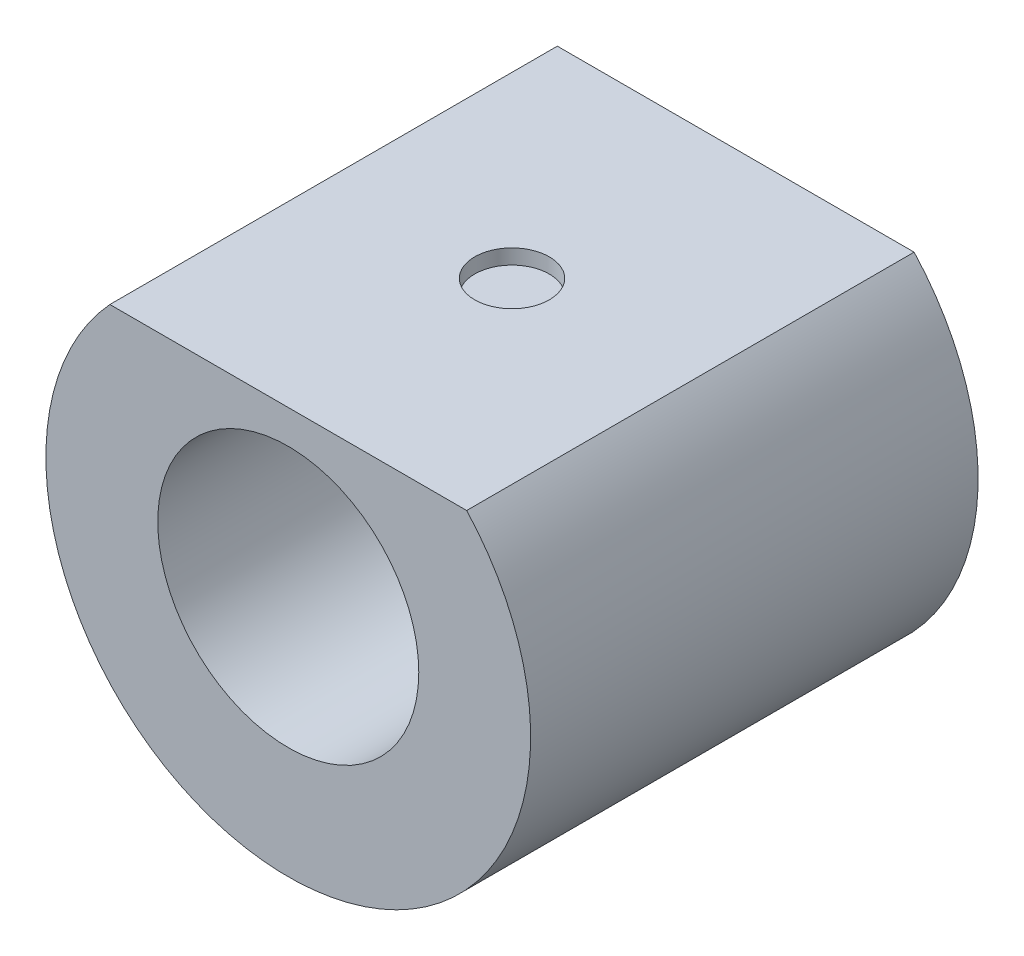
from build123d import *

# Parameters (mm, degrees)
SKETCH1_R           = 32.5
BOSS_EXTRUDE1_DEPTH = 60
SKETCH3_R           = 17.5
CUT_EXTRUDE4_DEPTH  = 52
SKETCH6_R           = 6.5
CUT_EXTRUDE5_DEPTH  = 8
SKETCH8_W           = 65.355871795
SKETCH8_H           = 11.921493712
CUT_EXTRUDE6_DEPTH  = 60
SKETCH9_R           = 5
CUT_EXTRUDE9_DEPTH  = 2


with BuildPart() as part:
    # Sketch1 → Boss-Extrude1 (new body)
    with BuildSketch(Plane.XY):
        Circle(SKETCH1_R)
    extrude(amount=BOSS_EXTRUDE1_DEPTH)

    # Sketch3 → Cut-Extrude4 (cut)
    with BuildSketch(Plane.XY.offset(60)):
        Circle(SKETCH3_R)
    extrude(amount=-CUT_EXTRUDE4_DEPTH, mode=Mode.SUBTRACT)

    # Sketch6 → Cut-Extrude5 (cut)
    with BuildSketch(Plane.XY.offset(8)):
        Circle(SKETCH6_R)
    extrude(amount=-CUT_EXTRUDE5_DEPTH, mode=Mode.SUBTRACT)

    # Sketch8 → Cut-Extrude6 (cut)
    with BuildSketch(Plane.XY.offset(60)):
        with Locations((-1.31264436, 27.960746856)):
            Rectangle(SKETCH8_W, SKETCH8_H)
    extrude(amount=-CUT_EXTRUDE6_DEPTH, mode=Mode.SUBTRACT)

    # Sketch9 → Cut-Extrude9 (cut)
    with BuildSketch(Plane(origin=(0, 22, 0), x_dir=(1, 0, 0), z_dir=(0, 1, 0))):
        with Locations(Location((0, -30, 0), (0, 0, 270))):  # turned: the seam where the file's is
            Circle(SKETCH9_R)
    extrude(amount=-CUT_EXTRUDE9_DEPTH, mode=Mode.SUBTRACT)


solid = part.part
